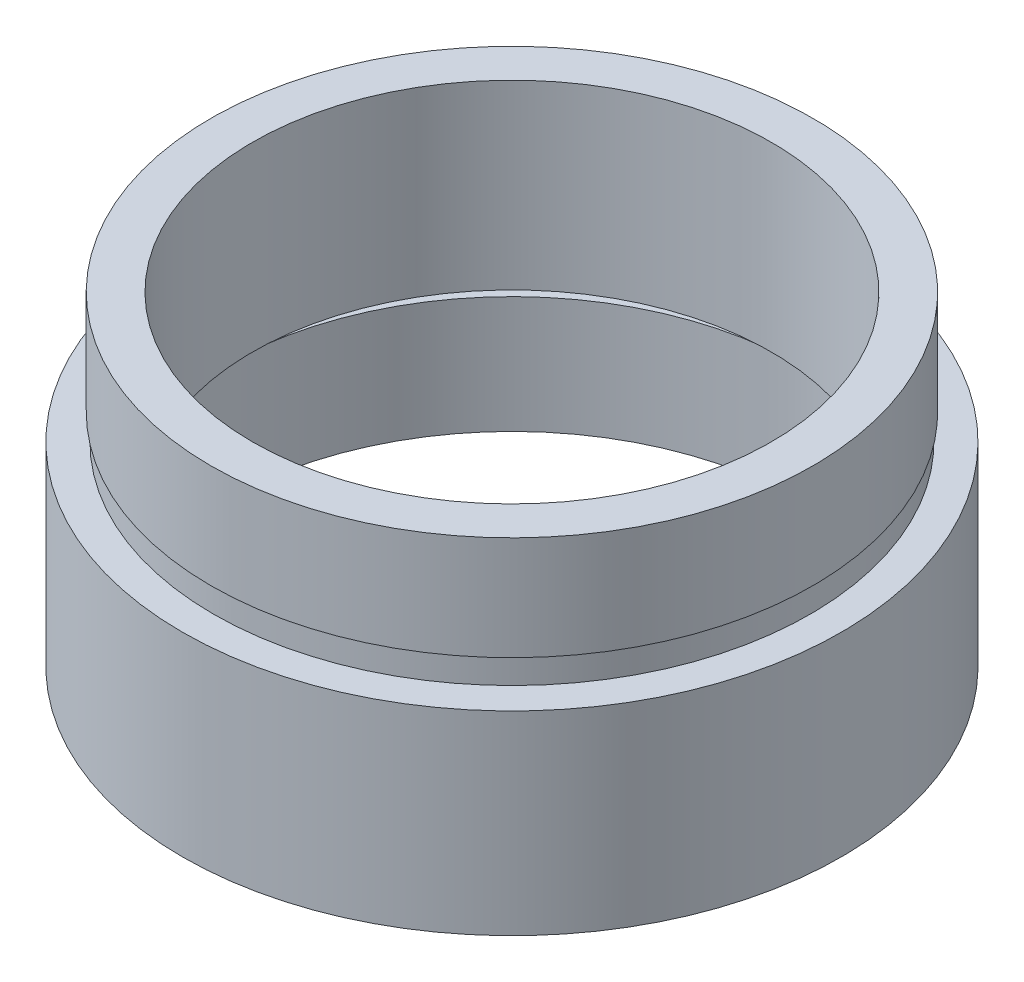
from build123d import *


with BuildPart() as part:
    # 草图1 → 旋转1 (revolve)
    with BuildSketch(Plane.XY, mode=Mode.PRIVATE) as revolve_1_sk:
        Polygon((12.7, 0), (12.7, 7.5), (11.5, 7.5), (11.5, 8.5), (11.6, 8.5), (11.6, 12.5), (10, 12.5), (10, 5.5), (11.7, 5.5), (11.7, 4.5), (11.1, 4.5), (11.1, 0), align=None)
    revolve(revolve_1_sk.sketch.rotate(Axis((0, 161.376166943, 0), (0, -1, 0)), 90), axis=Axis((0, 161.376166943, 0), (0, -1, 0)))  # turned: the seam where the file's is


solid = part.part
